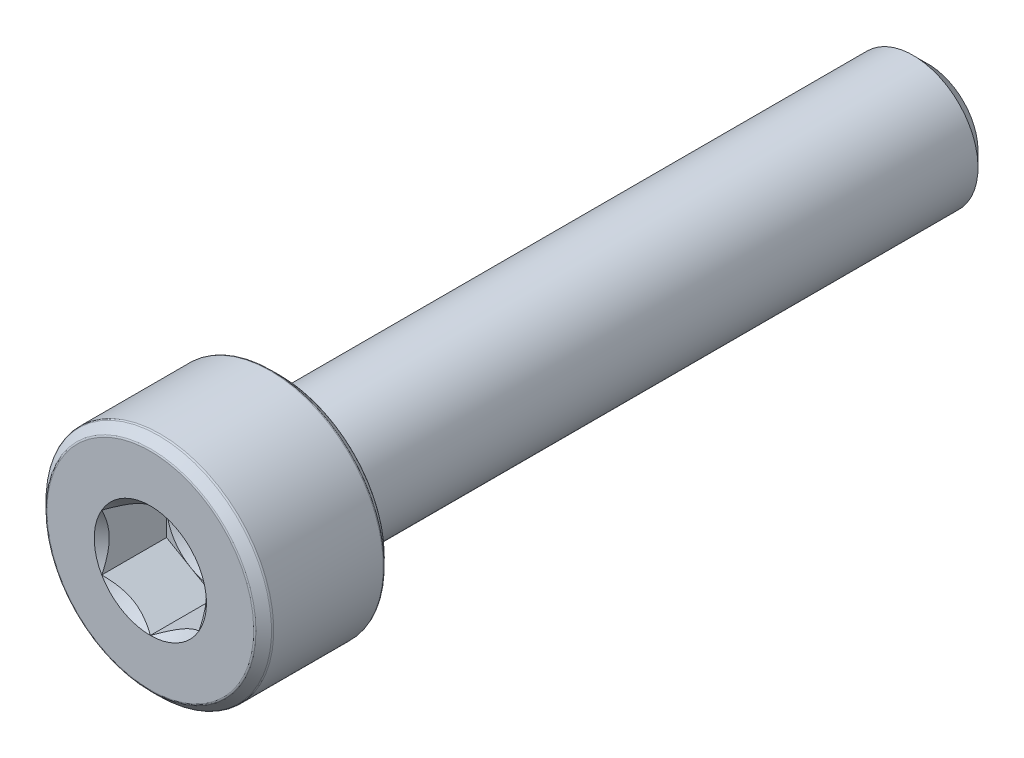
from build123d import *

# Parameters (mm, degrees)
CUT_EXTRUDE1_DEPTH = 2


with BuildPart() as part:
    # Sketch3 → Revolve1 (revolve)
    with BuildSketch(Plane(origin=(0, 0, 0), x_dir=(0, 0, -1), z_dir=(1, 0, 0)), mode=Mode.PRIVATE) as revolve1_sk:
        with BuildLine():
            Line((-12, 3.191005051), (-12, 1.5))
            Line((-12, 1.5), (-10, 1.5))
            Line((-10, 1.5), (-10, 0))
            Line((-10, 0), (12, 0))
            Line((12, 0), (12, 1.545336663))
            Line((12, 1.545336663), (11.545336663, 2))
            Line((11.545336663, 2), (-8, 2))
            Line((-8, 2), (-8, 3.191005051))
            ThreePointArc((-8, 3.191005051), (-8.005328433, 3.217792891), (-8.020502525, 3.240502525))
            Line((-8.020502525, 3.240502525), (-8.259497475, 3.479497475))
            ThreePointArc((-8.259497475, 3.479497475), (-8.282207109, 3.494671567), (-8.308994949, 3.5))
            Line((-8.308994949, 3.5), (-11.691005051, 3.5))
            ThreePointArc((-11.691005051, 3.5), (-11.717792891, 3.494671567), (-11.740502525, 3.479497475))
            Line((-11.740502525, 3.479497475), (-11.979497475, 3.240502525))
            ThreePointArc((-11.979497475, 3.240502525), (-11.994671567, 3.217792891), (-12, 3.191005051))
        make_face()
    revolve(revolve1_sk.sketch.rotate(Axis((0, 0, 12), (0, 0, -1)), 180), axis=Axis((0, 0, 12), (0, 0, -1)))

    # Sketch4 → Cut-Extrude1 (cut)
    with BuildSketch(Plane.XY.offset(12)):
        Polygon((0, 1.732050808), (-1.5, 0.866025404), (-1.5, -0.866025404), (0, -1.732050808), (1.5, -0.866025404), (1.5, 0.866025404), align=None)
    extrude(amount=-CUT_EXTRUDE1_DEPTH, mode=Mode.SUBTRACT)

    # Cut-Extrude2 cone 1 section (through the dimple's axis) → Cut-Extrude2 (revolve, cut)
    with BuildSketch(Plane(origin=(0, 0, 12), x_dir=(0, -1, 0), z_dir=(1, 0, 0))):
        Polygon((0, 0), (1.732050808, 0), (0, 1.732050808), align=None)
    revolve(axis=Axis((0, 0, 12), (0, 0, -1)), mode=Mode.SUBTRACT)

    # Cut-Extrude3 cone 1 section (through the dimple's axis) → Cut-Extrude3 (revolve, cut)
    with BuildSketch(Plane(origin=(0, 0, 10), x_dir=(0, -1, 0), z_dir=(1, 0, 0))):
        Polygon((0, 0), (1.5, 0), (0, 0.866025404), align=None)
    revolve(axis=Axis((0, 0, 10), (0, 0, -1)), mode=Mode.SUBTRACT)


solid = part.part
